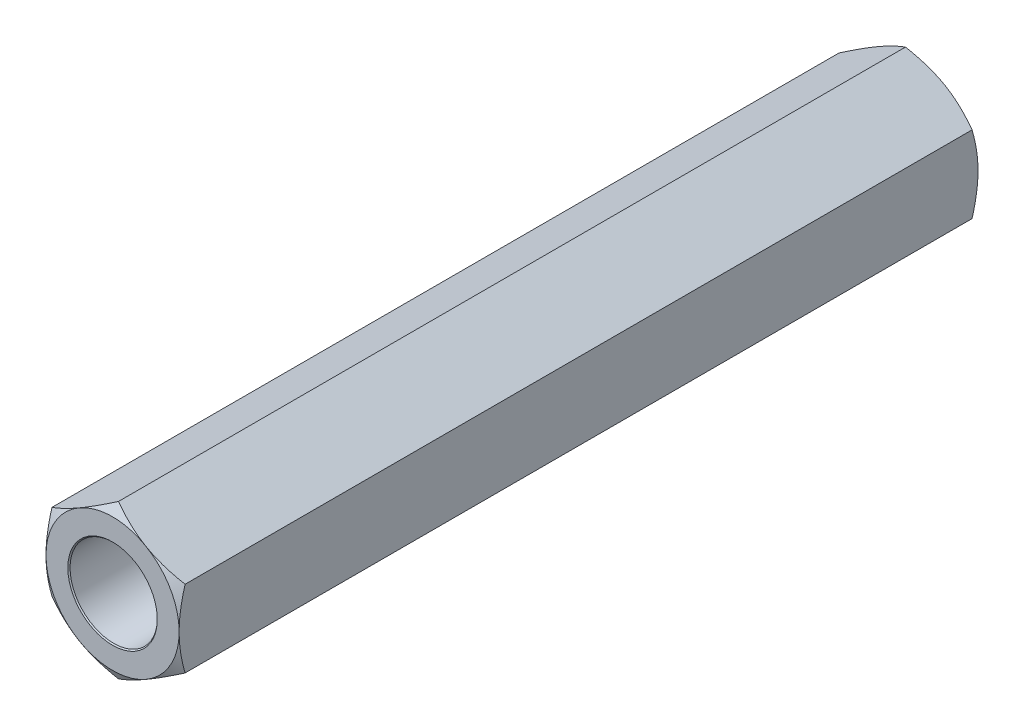
from build123d import *

# Parameters (mm, degrees)
EXTRUDE1_DEPTH          = 19.05
EXTRUDE1_DEPTH_BACK     = 19.05
SKETCH1_R               = 2.0828
SKETCH8_OUTSIDE_W       = 152.724
SKETCH8_OUTSIDE_H       = 153.706
SKETCH8_OUTSIDE_R       = 3.175
EXTRUDE4_DEPTH          = 39.407440143
EXTRUDE4_DRAFT          = -60
MIRROR1_COPY_1_SKETCH_W = 152.724
MIRROR1_COPY_1_SKETCH_H = 153.706
MIRROR1_COPY_1_SKETCH_R = 3.175
MIRROR1_COPY_1_DEPTH    = 39.407440143
MIRROR1_COPY_1_DRAFT    = -60


with BuildPart() as part:
    # Sketch1 → Extrude1 (new, two sides: drawn at the far end of the back side and taken through both)
    with BuildSketch(Plane.XY.offset(-EXTRUDE1_DEPTH_BACK)):
        Polygon((0, 3.666174209), (-3.175, 1.833087105), (-3.175, -1.833087105), (0, -3.666174209), (3.175, -1.833087105), (3.175, 1.833087105), align=None)
        with Locations(Location((0, 0, 0), (0, 0, 180))):
            Circle(SKETCH1_R, mode=Mode.SUBTRACT)
    extrude(amount=EXTRUDE1_DEPTH + EXTRUDE1_DEPTH_BACK)

    # Extrude3 cone 1 section (through the dimple's axis) → Extrude3 (revolve, cut)
    with BuildSketch(Plane(origin=(0, 0, -19.05), x_dir=(0, 1, 0), z_dir=(1, 0, 0))):
        Polygon((0, 0), (2.1336, 0), (0, 2.28800588), align=None)
    extrude3 = revolve(axis=Axis((0, 0, -19.05), (0, 0, 1)), mode=Mode.SUBTRACT)


with BuildPart() as extrude4_tool:
    # Sketch8 outside → Extrude4 (with draft: the straight prism first)
    with BuildSketch(Plane(origin=(0, 0, -19.05), x_dir=(-1, 0, 0), z_dir=(0, 0, -1))):
        Rectangle(SKETCH8_OUTSIDE_W, SKETCH8_OUTSIDE_H)
        Circle(SKETCH8_OUTSIDE_R, mode=Mode.SUBTRACT)
    extrude(amount=-EXTRUDE4_DEPTH)
    # Extrude4: the draft: its side faces are tilted about the plane it starts from
    extrude4_sides = [extrude4_tool.faces().sort_by_distance(p)[0] for p in [
        (0, -76.853, 0.653720071),
        (-76.362, 0, 0.653720071),
        (0, 76.853, 0.653720071),
        (76.362, 0, 0.653720071),
        (3.175, 0, 0.653720071),
    ]]
    draft(extrude4_sides, Plane(origin=(0, 0, -19.05), x_dir=(-1, 0, 0), z_dir=(0, 0, -1)), EXTRUDE4_DRAFT)


with BuildPart() as part_1:
    add(part.part)

    # Extrude4: cut by extrude4_tool
    add(extrude4_tool.part, mode=Mode.SUBTRACT)

    # Mirror1: Extrude3 across plane
    add(extrude3.mirror(Plane.XY), mode=Mode.SUBTRACT)


with BuildPart() as mirror1_copy_1_tool:
    # Mirror1 copy 1 sketch → Mirror1 copy 1 (with draft: the straight prism first)
    with BuildSketch(Plane(origin=(0, 0, 19.05), x_dir=(-1, 0, 0), z_dir=(0, 0, 1))):
        Rectangle(MIRROR1_COPY_1_SKETCH_W, MIRROR1_COPY_1_SKETCH_H)
        Circle(MIRROR1_COPY_1_SKETCH_R, mode=Mode.SUBTRACT)
    extrude(amount=-MIRROR1_COPY_1_DEPTH)
    # Mirror1 copy 1: the draft: its side faces are tilted about the plane it starts from
    mirror1_copy_1_sides = [mirror1_copy_1_tool.faces().sort_by_distance(p)[0] for p in [
        (0, -76.853, -0.653720071),
        (-76.362, 0, -0.653720071),
        (0, 76.853, -0.653720071),
        (76.362, 0, -0.653720071),
        (3.175, 0, -0.653720071),
    ]]
    draft(mirror1_copy_1_sides, Plane(origin=(0, 0, 19.05), x_dir=(-1, 0, 0), z_dir=(0, 0, 1)), MIRROR1_COPY_1_DRAFT)


with BuildPart() as part_2:
    add(part_1.part)

    # Mirror1 copy 1: cut by mirror1_copy_1_tool
    add(mirror1_copy_1_tool.part, mode=Mode.SUBTRACT)


solid = part_2.part
